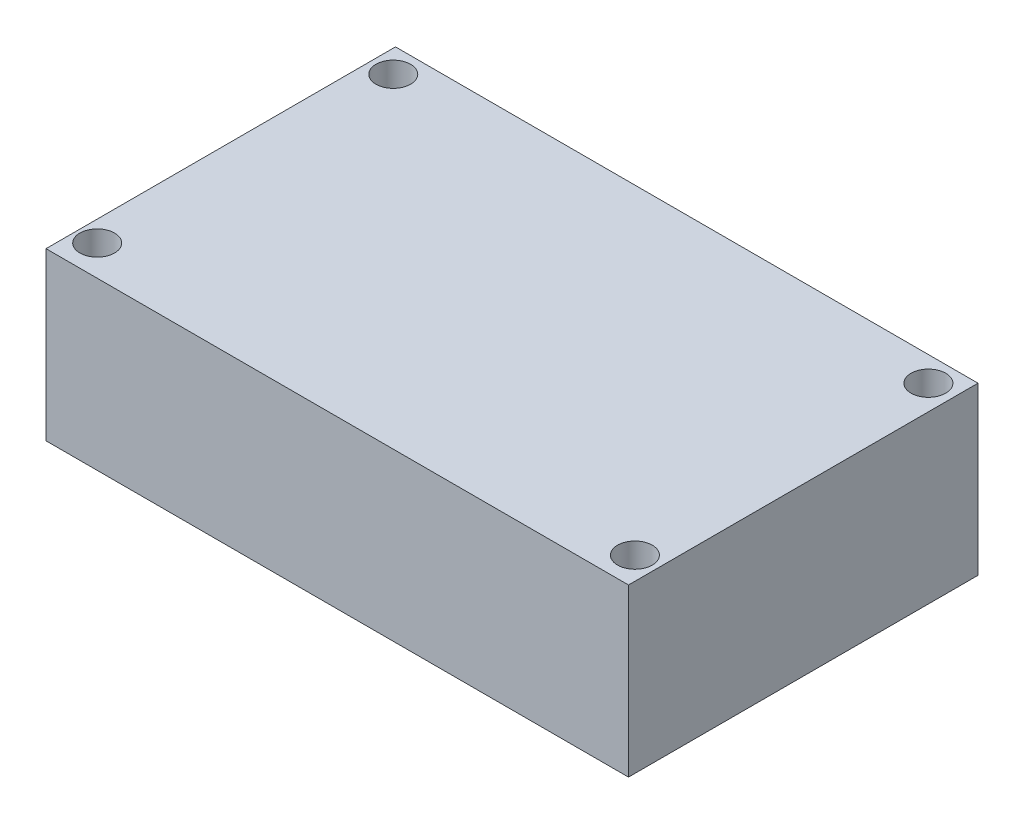
from build123d import *

# Parameters (mm, degrees)
SKETCH1_W           = 42
SKETCH1_H           = 25.2
BOSS_EXTRUDE1_DEPTH = 12
SKETCH2_R           = 1.25
CUT_EXTRUDE1_DEPTH  = 20


with BuildPart() as part:
    # Sketch1 → Boss-Extrude1 (new body)
    with BuildSketch(Plane(origin=(0, 0, 0), x_dir=(1, 0, 0), z_dir=(0, 1, 0))):
        Rectangle(SKETCH1_W, SKETCH1_H)
    extrude(amount=BOSS_EXTRUDE1_DEPTH)

    # Sketch2 → Cut-Extrude1 (cut)
    with BuildSketch(Plane(origin=(0, 12, 0), x_dir=(1, 0, 0), z_dir=(0, 1, 0))):
        with Locations((-19.3711958, 10.809635356)):
            Circle(SKETCH2_R)
        with Locations((-19.504807582, -10.403211158)):
            Circle(SKETCH2_R)
        with Locations((19.368191176, -10.507005442)):
            Circle(SKETCH2_R)
        with Locations((19.213792616, 10.809635356)):
            Circle(SKETCH2_R)
    extrude(amount=-CUT_EXTRUDE1_DEPTH, mode=Mode.SUBTRACT)


solid = part.part
